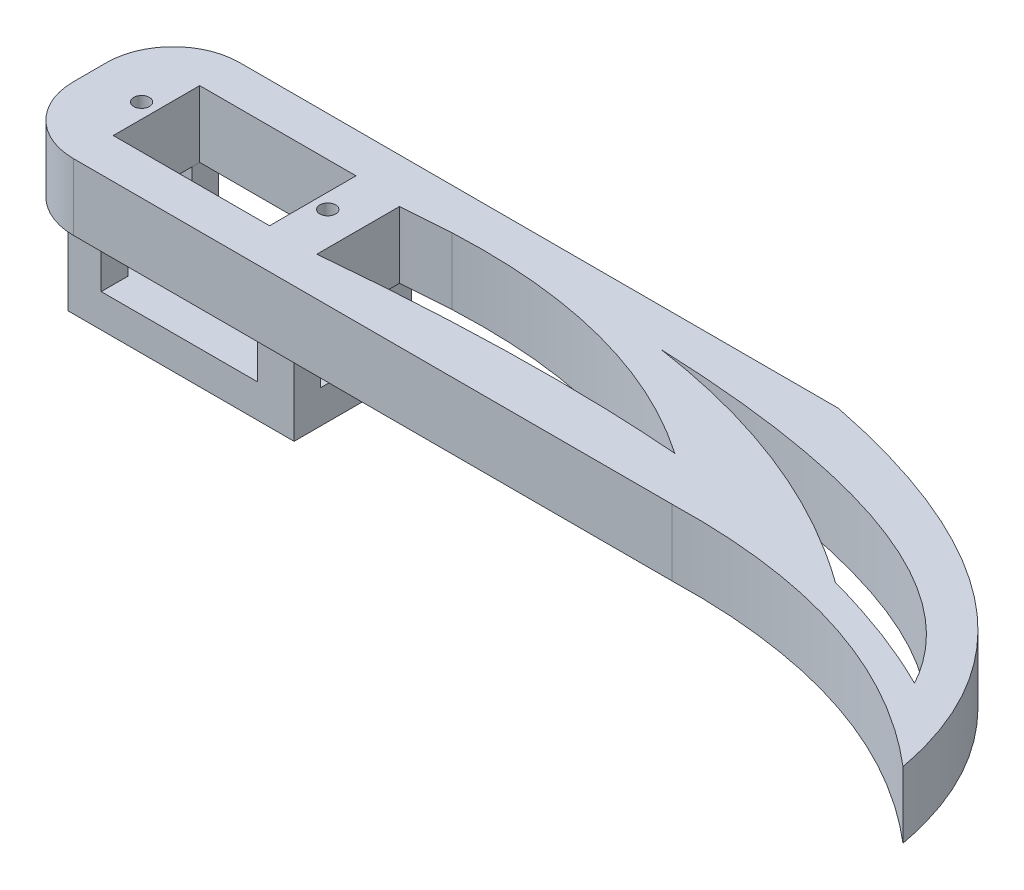
from build123d import *

# Parameters (mm, degrees)
SKETCH1_W           = 100
SKETCH1_H           = 25
BOSS_EXTRUDE1_DEPTH = 10
SKETCH2_R           = 1.19
SKETCH2_W           = 23.5
SKETCH2_H           = 13
CUT_EXTRUDE1_DEPTH  = 10
BOSS_EXTRUDE2_DEPTH = 10
FILLET1_R           = 10
SKETCH7_W           = 34
SKETCH7_H           = 17.658274854
BOSS_EXTRUDE3_DEPTH = 14.5
SKETCH8_W           = 23.5
SKETCH8_H           = 9.5
CUT_EXTRUDE2_DEPTH  = 21.735155199
SKETCH9_W           = 9.658274854
SKETCH9_H           = 9.5
CUT_EXTRUDE3_DEPTH  = 147.612554477
SKETCH10_R          = 2.899136991
BOSS_EXTRUDE4_DEPTH = 5
CUT_EXTRUDE4_DEPTH  = 30.5


with BuildPart() as part:
    # Sketch1 → Boss-Extrude1 (new body)
    with BuildSketch(Plane(origin=(0, 0, 0), x_dir=(1, 0, 0), z_dir=(0, 1, 0))):
        with Locations((50, 12.5)):
            Rectangle(SKETCH1_W, SKETCH1_H)
    extrude(amount=BOSS_EXTRUDE1_DEPTH)

    # Sketch2 → Cut-Extrude1 (cut)
    with BuildSketch(Plane(origin=(0, 10, 0), x_dir=(1, 0, 0), z_dir=(0, 1, 0))):
        with Locations((7.75, 12.5)):
            Circle(SKETCH2_R)
        with Locations((35.75, 12.5)):
            Circle(SKETCH2_R)
        with Locations((21.75, 12.5)):
            Rectangle(SKETCH2_W, SKETCH2_H)
    extrude(amount=-CUT_EXTRUDE1_DEPTH, mode=Mode.SUBTRACT)

    # Sketch3 → Boss-Extrude2 (add)
    with BuildSketch(Plane(origin=(0, 10, 0), x_dir=(1, 0, 0), z_dir=(0, 1, 0))):
        with BuildLine():
            add(Edge.make_bspline(
                [(100, 0), (130.91054584, 0.791905692), (151.535957226, -16.787524717)],
                knots=[0, 0, 0, 1, 1, 1], degree=2))
            add(Edge.make_bspline(
                [(100, 25), (145.583275761, 15.848400437), (151.535957226, -16.787524717)],
                knots=[0, 0, 0, 1, 1, 1], degree=2))
            Line((100, 25), (100, 0))
        make_face()
    extrude(amount=-BOSS_EXTRUDE2_DEPTH)

    # Fillet1
    fillet1_edges = [part.edges().sort_by_distance(p)[0] for p in [
        (0, 5, -25),
        (0, 5, 0),
    ]]
    fillet(fillet1_edges, radius=FILLET1_R)

    # Sketch7 → Boss-Extrude3 (add)
    with BuildSketch(Plane.XZ):
        with Locations((21.923402849, -13.093982328)):
            Rectangle(SKETCH7_W, SKETCH7_H)
    extrude(amount=BOSS_EXTRUDE3_DEPTH)

    # Sketch8 → Cut-Extrude2 (cut, through all)
    with BuildSketch(Plane.XY.offset(-4.264844901)):
        with Locations((21.673402849, -4.75)):
            Rectangle(SKETCH8_W, SKETCH8_H)
    extrude(amount=-CUT_EXTRUDE2_DEPTH, mode=Mode.SUBTRACT)

    # Sketch9 → Cut-Extrude3 (cut, through all)
    with BuildSketch(Plane.ZY.offset(-4.923402849)):
        with Locations((-13.093982328, -4.75)):
            Rectangle(SKETCH9_W, SKETCH9_H)
    extrude(amount=-CUT_EXTRUDE3_DEPTH, mode=Mode.SUBTRACT)

    # Sketch10 → Boss-Extrude4 (add)
    with BuildSketch(Plane.XZ.offset(14.5)):
        with Locations((16.5, -12.5)):
            Circle(SKETCH10_R)
    extrude(amount=BOSS_EXTRUDE4_DEPTH)

    # Sketch13 → Cut-Extrude4 (cut, through all)
    with BuildSketch(Plane(origin=(0, 10, 0), x_dir=(1, 0, 0), z_dir=(0, 1, 0))):
        with BuildLine():
            Line((40.759141507, 18.280493838), (40.759141507, 13.958351936))
            Line((40.759141507, 13.958351936), (40.759141507, 5.850917493))
            add(Edge.make_bspline(
                [(40.759141507, 5.850917493), (70.418760449, 8.670764937), (93.626937349, 6.822983821)],
                knots=[0, 0, 0, 0.76207728, 0.76207728, 0.76207728], degree=2))
            add(Edge.make_bspline(
                [(48.109032445, 18.802566203), (74.292639641, 20.065268225), (93.626937349, 6.822983821)],
                knots=[0, 0, 0, 0.932257027, 0.932257027, 0.932257027], degree=2))
            add(Edge.make_bspline(
                [(40.759141507, 18.280493838), (44.500946657, 18.577601375), (48.109032445, 18.802566203)],
                knots=[0, 0, 0, 0.044284704, 0.044284704, 0.044284704], degree=2))
        make_face()
        with BuildLine():
            add(Edge.make_bspline(
                [(79.05980568, 19.324038395), (129.368985963, 17.399904925), (141.56306601, -5.087642347)],
                knots=[0.252338304, 0.252338304, 0.252338304, 1, 1, 1], degree=2))
            add(Edge.make_bspline(
                [(79.05980568, 19.324038395), (103.573343897, 15.754713023), (122.487748371, 2.098418722)],
                knots=[0, 0, 0, 0.958850714, 0.958850714, 0.958850714], degree=2))
            add(Edge.make_bspline(
                [(122.487748371, 2.098418722), (125.30805626, 1.325368592), (128.089706455, 0.417067533)],
                knots=[0.632770601, 0.632770601, 0.632770601, 0.8750054, 0.8750054, 0.8750054], degree=2))
            add(Edge.make_bspline(
                [(128.089706455, 0.417067533), (129.541401077, -0.054077042), (130.95010952, -0.556322186)],
                knots=[0, 0, 0, 0.199498744, 0.199498744, 0.199498744], degree=2))
            add(Edge.make_bspline(
                [(130.95010952, -0.556322186), (136.602640718, -2.571612406), (141.56306601, -5.087642347)],
                knots=[0.199498744, 0.199498744, 0.199498744, 1, 1, 1], degree=2))
        make_face()
    extrude(amount=-CUT_EXTRUDE4_DEPTH, mode=Mode.SUBTRACT)


solid = part.part
